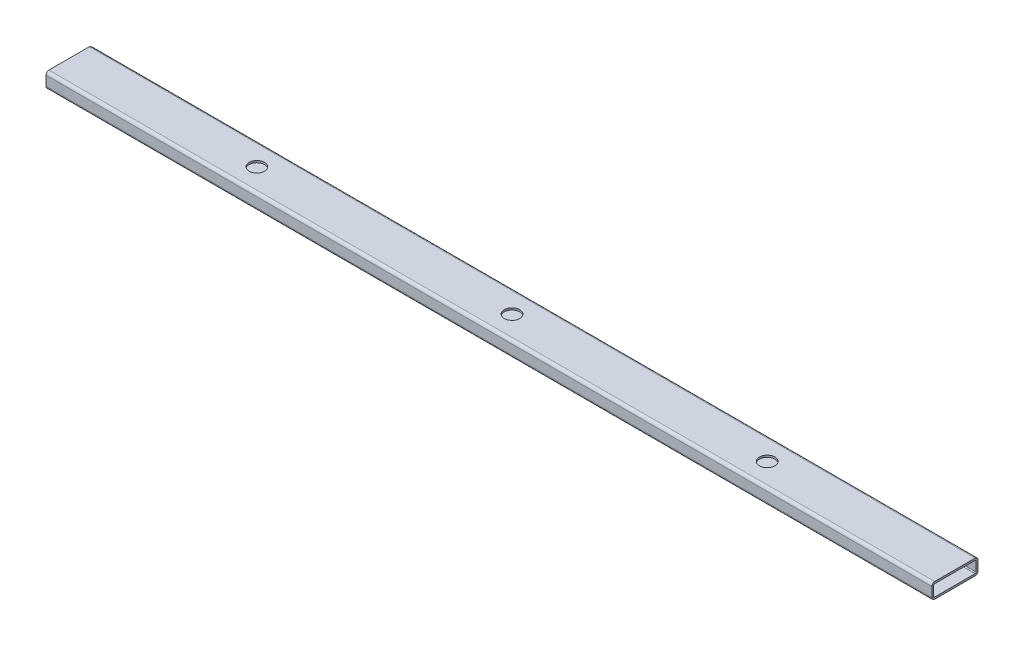
from build123d import *

# Parameters (mm, degrees)
BOSS_EXTRUDE1_DEPTH = 730.25
SKETCH2_R           = 12.7
CUT_EXTRUDE1_DEPTH  = 3.175
LPATTERN1_COUNT     = 3
LPATTERN1_PITCH     = 420.6875


with BuildPart() as part:
    # Sketch1 → Boss-Extrude1 (new body, symmetric)
    with BuildSketch(Plane(origin=(0, 0, 0), x_dir=(0, 0, -1), z_dir=(1, 0, 0))):
        with BuildLine():
            Line((33.3248, 25.4), (-33.3248, 25.4))
            ThreePointArc((-33.3248, 25.4), (-36.701376302, 24.001376302), (-38.1, 20.6248))
            Line((-38.1, 20.6248), (-38.1, 4.7752))
            ThreePointArc((-38.1, 4.7752), (-36.701376302, 1.398623698), (-33.3248, 0))
            Line((-33.3248, 0), (33.3248, 0))
            ThreePointArc((33.3248, 0), (36.701376302, 1.398623698), (38.1, 4.7752))
            Line((38.1, 4.7752), (38.1, 20.6248))
            ThreePointArc((38.1, 20.6248), (36.701376302, 24.001376302), (33.3248, 25.4))
        make_face()
        with BuildLine():
            Line((33.3248, 22.225), (-33.3248, 22.225))
            ThreePointArc((-33.3248, 22.225), (-34.456312271, 21.756312271), (-34.925, 20.6248))
            Line((-34.925, 20.6248), (-34.925, 4.7752))
            ThreePointArc((-34.925, 4.7752), (-34.456312271, 3.643687729), (-33.3248, 3.175))
            Line((-33.3248, 3.175), (33.3248, 3.175))
            ThreePointArc((33.3248, 3.175), (34.456312271, 3.643687729), (34.925, 4.7752))
            Line((34.925, 4.7752), (34.925, 20.6248))
            ThreePointArc((34.925, 20.6248), (34.456312271, 21.756312271), (33.3248, 22.225))
        make_face(mode=Mode.SUBTRACT)
    extrude(amount=BOSS_EXTRUDE1_DEPTH, both=True)

    # Sketch2 → Cut-Extrude1 (cut)
    with BuildSketch(Plane(origin=(0, 25.4, 0), x_dir=(1, 0, 0), z_dir=(0, 1, 0))):
        with Locations((-420.6875, 0)):
            Circle(SKETCH2_R)
    cut_extrude1 = extrude(amount=-CUT_EXTRUDE1_DEPTH, mode=Mode.SUBTRACT)

    # LPattern1: Cut-Extrude1 ×3
    with Locations(*[(i * LPATTERN1_PITCH, 0, 0) for i in range(1, LPATTERN1_COUNT)]):
        add(cut_extrude1, mode=Mode.SUBTRACT)


solid = part.part
